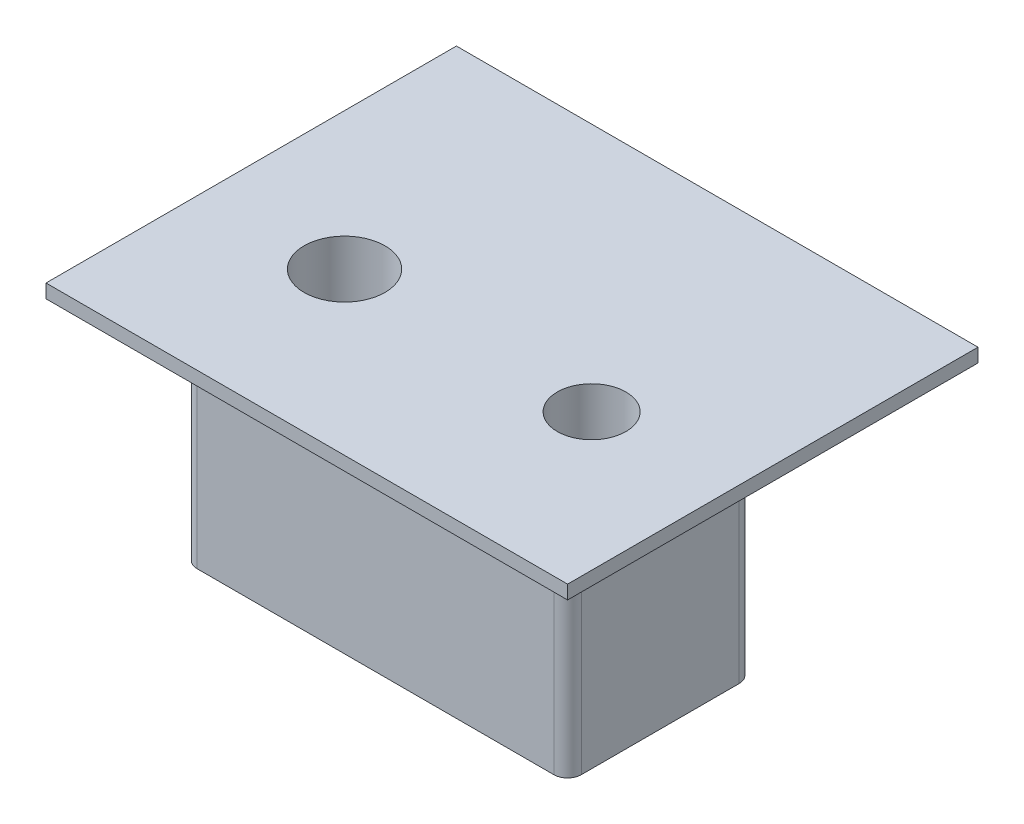
from build123d import *

# Parameters (mm, degrees)
SKETCH1_W           = 14
SKETCH1_H           = 8.2625
EXTRUDE1_DEPTH      = 3.375
SKETCH4_W           = 19
SKETCH4_H           = 11.75
EXTRUDE2_DEPTH      = 0.5
SKETCH2_W           = 1.4732
SKETCH2_H           = 16.500973173
SKETCH3_W           = 1.25
SKETCH3_H           = 20
FILLET1_R           = 0.5
SKETCH6_W           = 19
SKETCH6_H           = 0.5
BOSS_EXTRUDE2_DEPTH = 3.2


with BuildPart() as part:
    # Sketch1 → Extrude1 (new body, symmetric)
    with BuildSketch(Plane.XY):
        with Locations((0, 189.13125)):
            Rectangle(SKETCH1_W, SKETCH1_H)
    extrude(amount=EXTRUDE1_DEPTH, both=True)

    # Sketch4 → Extrude2 (add)
    with BuildSketch(Plane(origin=(0, 193.2625, 0), x_dir=(1, 0, 0), z_dir=(0, 1, 0))):
        Rectangle(SKETCH4_W, SKETCH4_H)
    extrude(amount=EXTRUDE2_DEPTH)

    # Sketch2 → Cut-Revolve1 (revolve, cut)
    with BuildSketch(Plane(origin=(9.451328919, 219.930638069, 0), x_dir=(1, 0, 0), z_dir=(0, 0, -1)), mode=Mode.PRIVATE) as cut_revolve1_sk:
        with Locations((-13.214728919, 29.739409073)):
            Rectangle(SKETCH2_W, SKETCH2_H)
    revolve(cut_revolve1_sk.sketch.rotate(Axis((-4.5, 202.803113019, 0), (0, -1, 0)), 90), axis=Axis((-4.5, 202.803113019, 0), (0, -1, 0)), mode=Mode.SUBTRACT)  # turned: the seam where the file's is

    # Sketch3 → Cut-Revolve2 (revolve, cut)
    with BuildSketch(Plane.XY, mode=Mode.PRIVATE) as cut_revolve2_sk:
        with Locations((5.125, 191.895853695)):
            Rectangle(SKETCH3_W, SKETCH3_H)
    revolve(cut_revolve2_sk.sketch.rotate(Axis((4.5, 219.496854939, 0), (0, -1, 0)), 90), axis=Axis((4.5, 219.496854939, 0), (0, -1, 0)), mode=Mode.SUBTRACT)  # turned: the seam where the file's is

    # Fillet1
    fillet1_edges = [part.edges().sort_by_distance(p)[0] for p in [
        (7, 189.13125, 3.375),
        (-7, 189.13125, 3.375),
        (7, 189.13125, -3.375),
        (-7, 189.13125, -3.375),
    ]]
    fillet(fillet1_edges, radius=FILLET1_R)

    # Sketch6 → Boss-Extrude2 (add)
    with BuildSketch(Plane(origin=(0, 0, -5.875), x_dir=(-1, 0, 0), z_dir=(0, 0, -1))):
        with Locations((0, 193.5125)):
            Rectangle(SKETCH6_W, SKETCH6_H)
    extrude(amount=BOSS_EXTRUDE2_DEPTH)


solid = part.part
